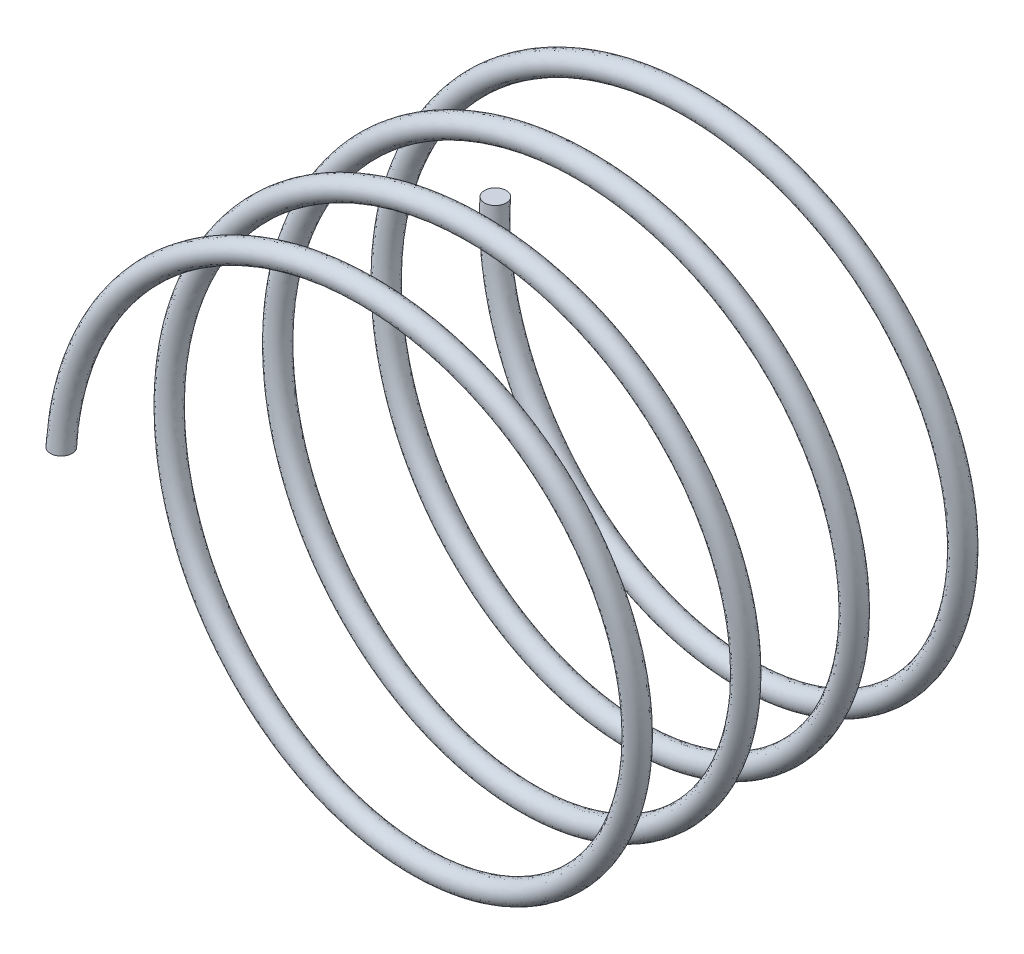
from build123d import *

# Parameters (mm, degrees)
SWEEP1_PITCH  = 25
SWEEP1_HEIGHT = 100
SWEEP1_RADIUS = 60
SKETCH3_R     = 2.5


with BuildPart() as part:
    # Sweep1: sweep along a helix
    with BuildLine() as sweep1_path:
        Helix(SWEEP1_PITCH, SWEEP1_HEIGHT, SWEEP1_RADIUS, center=(0, 0, 0), direction=(0, 0, -1))
    # Sketch3 → Sweep1 (sweep)
    with BuildSketch(Plane(origin=(0, 0, 0), x_dir=(1, 0, 0), z_dir=(0, 1, 0))):
        with Locations((-60.023147398, 0)):
            Circle(SKETCH3_R)
    sweep(path=sweep1_path.line, is_frenet=True)


solid = part.part
